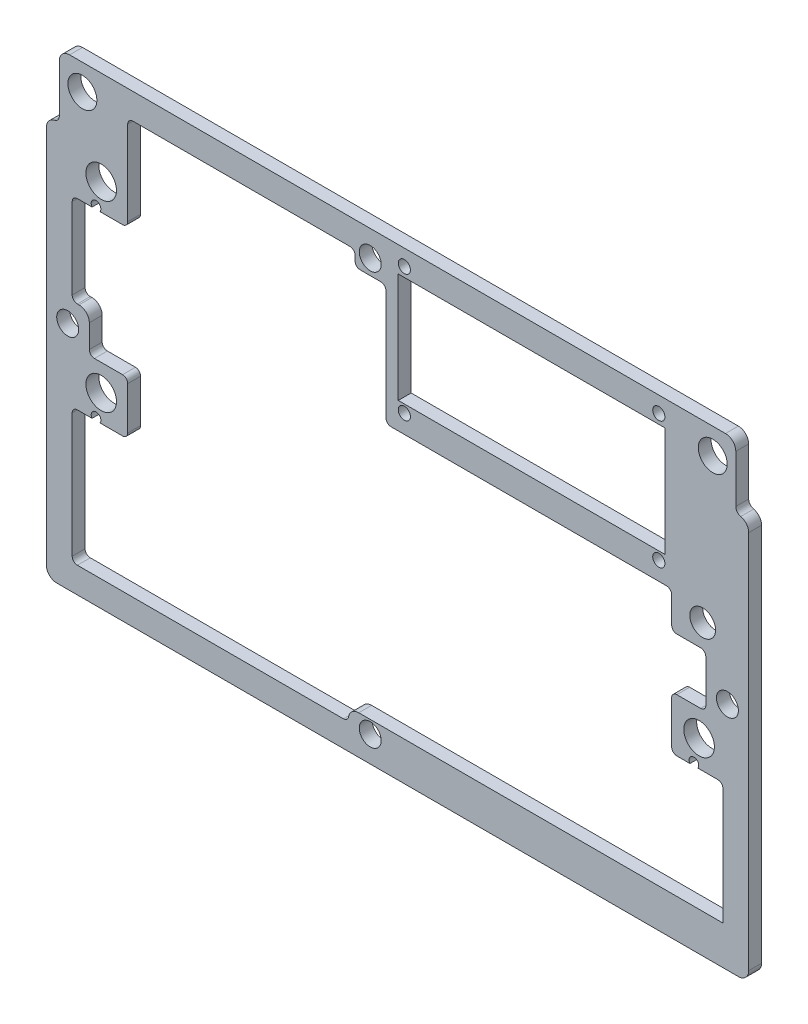
from build123d import *

# Parameters (mm, degrees)
SKETCH1_W                   = 173.0375
SKETCH1_H                   = 114.3
BOSS_EXTRUDE1_DEPTH         = 3.175
SKETCH3_R                   = 3.175
SKETCH3_R_2                 = 3.7703125
CUT_EXTRUDE1_DEPTH          = 4.175
F_6_CLEARANCE_HOLE1_D       = 4.3053
F_2_CLEARANCE_HOLE1_D       = 2.7051
SKETCH8_W                   = 58.74
SKETCH8_H                   = 26.99
CUT_EXTRUDE2_DEPTH          = 4.175
F_3_0_213_DIAMETER_HOLE1_D  = 5.4102
F_3_0_3_DIAMETER_HOLE1_D    = 3
FILLET1_R                   = 1.27
FILLET2_R                   = 2.54
F_1_4_CLEARANCE_HOLE1_D     = 7.14248
F_1_4_CLEARANCE_HOLE1_DEPTH = 3.175
CUT_EXTRUDE3_REACH          = 5.175
SKETCH14_W                  = 3.175
SKETCH14_H                  = 15.875
FILLET3_R                   = 1.5875
FILLET4_R                   = 2.54
CUT_EXTRUDE4_START          = -3.175
SKETCH15_W                  = 65.7
SKETCH15_H                  = 26.99
CUT_EXTRUDE4_DEPTH          = 3.175
CUT_EXTRUDE5_REACH          = 5.175
SKETCH16_R                  = 1.190625


with BuildPart() as part:
    # Sketch1 → Boss-Extrude1 (new body)
    with BuildSketch(Plane.XY):
        with Locations((25.118, -40.513)):
            Rectangle(SKETCH1_W, SKETCH1_H)
    extrude(amount=BOSS_EXTRUDE1_DEPTH)

    # Sketch3 → Cut-Extrude1 (cut, through all)
    with BuildSketch(Plane.XY.offset(3.175)):
        with Locations((100.302, -26.543)):
            Circle(SKETCH3_R)
        with Locations((99.413, -51.6255)):
            Circle(SKETCH3_R_2)
        with Locations((-47.907, -51.6255)):
            Circle(SKETCH3_R_2)
        with Locations((-47.907, -6.5405)):
            Circle(SKETCH3_R_2)
    extrude(amount=-CUT_EXTRUDE1_DEPTH, mode=Mode.SUBTRACT)

    # #6 Clearance Hole1 (through all)
    with Locations(Plane.XY.offset(3.175)):
        with Locations((18.387, 10.287), (-56.162, -40.894), (106.398, -40.894), (18.387, -91.313)):
            Hole(F_6_CLEARANCE_HOLE1_D / 2)

    # #2 Clearance Hole1 (through all)
    with Locations(Plane.XY.offset(3.175)):
        with Locations((26.788, 12.7), (89.488, 12.7), (89.488, -18.6), (26.788, -18.6)):
            Hole(F_2_CLEARANCE_HOLE1_D / 2)

    # Sketch8 → Cut-Extrude2 (cut, through all)
    with BuildSketch(Plane.XY.offset(3.175)):
        with Locations((58.138, -3.125)):
            Rectangle(SKETCH8_W, SKETCH8_H)
        Polygon((14.64685, 6.54685), (14.64685, 10.287), (-41.367, 10.287), (-41.367, -13.0805), (-55.05075, -13.0805), (-55.05075, -35.56635), (-50.83435, -35.56635), (-50.83435, -45.0855), (-41.367, -45.0855), (-41.367, -58.1655), (-55.05075, -58.1655), (-55.05075, -91.313), (13.05935, -91.313), (13.05935, -88.138), (105.28675, -88.138), (105.28675, -58.1655), (92.658, -58.1655), (92.658, -45.0855), (101.07035, -45.0855), (101.07035, -32.150898303), (92.658, -32.150898303), (92.658, -23.12755), (22.26045, -23.12755), (22.26045, 6.54685), align=None)
    extrude(amount=-CUT_EXTRUDE2_DEPTH, mode=Mode.SUBTRACT)

    # #3 (0.213) Diameter Hole1 (through all)
    with Locations(Plane(origin=(18.387, 10.287, 3.175), x_dir=(1, 0, 0), z_dir=(0, 0, 1))):
        with Locations((0, 0), (-74.549, -51.181), (0, -101.6), (88.011, -51.181)):
            Hole(F_3_0_213_DIAMETER_HOLE1_D / 2)

    # Ø3.0 (3) Diameter Hole1 (through all)
    with Locations(Plane.XY.offset(3.175)):
        with Locations((26.788, 12.7), (89.488, 12.7), (89.488, -18.6), (26.788, -18.6)):
            Hole(F_3_0_3_DIAMETER_HOLE1_D / 2)

    # Fillet1
    fillet1_edges = [part.edges().sort_by_distance(p)[0] for p in [
        (14.64685, 10.287, 1.5875),
        (14.64685, 6.54685, 1.5875),
        (22.26045, 6.54685, 1.5875),
        (22.26045, -23.12755, 1.5875),
        (92.658, -23.12755, 1.5875),
        (92.658, -32.150898303, 1.5875),
        (101.07035, -32.150898303, 1.5875),
        (101.07035, -45.0855, 1.5875),
        (92.658, -45.0855, 1.5875),
        (92.658, -58.1655, 1.5875),
        (105.28675, -58.1655, 1.5875),
        (13.05935, -91.313, 1.5875),
        (-55.05075, -91.313, 1.5875),
        (-55.05075, -58.1655, 1.5875),
        (-41.367, -58.1655, 1.5875),
        (-41.367, -45.0855, 1.5875),
        (-50.83435, -45.0855, 1.5875),
        (-55.05075, -35.56635, 1.5875),
        (-55.05075, -13.0805, 1.5875),
        (-41.367, -13.0805, 1.5875),
        (-41.367, 10.287, 1.5875),
    ]]
    fillet(fillet1_edges, radius=FILLET1_R)

    # Fillet2
    fillet2_edges = [part.edges().sort_by_distance(p)[0] for p in [
        (13.05935, -88.138, 1.5875),
        (-50.83435, -35.56635, 1.5875),
        (111.63675, 16.637, 1.5875),
        (111.63675, -97.663, 1.5875),
        (-61.40075, -97.663, 1.5875),
        (-61.40075, 16.637, 1.5875),
    ]]
    fillet(fillet2_edges, radius=FILLET2_R)

    # 1/4 Clearance Hole1
    with Locations(Plane(origin=(0, 0, 0), x_dir=(-1, 0, 0), z_dir=(0, 0, -1))):
        with Locations((-102.7785, 10.287), (52.5425, 10.287)):
            Hole(F_1_4_CLEARANCE_HOLE1_D / 2, depth=F_1_4_CLEARANCE_HOLE1_DEPTH)

    # Sketch14 → Cut-Extrude3 (cut, up to next)
    with BuildSketch(Plane(origin=(0, 0, 0), x_dir=(-1, 0, 0), z_dir=(0, 0, -1)), mode=Mode.PRIVATE) as cut_extrude3_sk1:
        with Locations((-110.04925, 8.6995)):
            Rectangle(SKETCH14_W, SKETCH14_H)
    cut_extrude3_tool1 = extrude(cut_extrude3_sk1.sketch, amount=-CUT_EXTRUDE3_REACH, mode=Mode.PRIVATE) & part.part
    add(cut_extrude3_tool1.solids().sort_by_distance((110.04925, 8.6995, 0))[0], mode=Mode.SUBTRACT)
    # Sketch14 → Cut-Extrude3 (cut, up to next)
    with BuildSketch(Plane(origin=(0, 0, 0), x_dir=(-1, 0, 0), z_dir=(0, 0, -1)), mode=Mode.PRIVATE) as cut_extrude3_sk2:
        with Locations((59.81325, 8.6995)):
            Rectangle(SKETCH14_W, SKETCH14_H)
    cut_extrude3_tool2 = extrude(cut_extrude3_sk2.sketch, amount=-CUT_EXTRUDE3_REACH, mode=Mode.PRIVATE) & part.part
    add(cut_extrude3_tool2.solids().sort_by_distance((-59.81325, 8.6995, 0))[0], mode=Mode.SUBTRACT)

    # Fillet3
    fillet3_edges = [part.edges().sort_by_distance(p)[0] for p in [
        (108.46175, 0.762, 1.5875),
        (-58.22575, 0.762, 1.5875),
    ]]
    fillet(fillet3_edges, radius=FILLET3_R)

    # Fillet4
    fillet4_edges = [part.edges().sort_by_distance(p)[0] for p in [
        (111.63675, 0.762, 1.5875),
        (108.46175, 16.637, 1.5875),
        (-58.22575, 16.637, 1.5875),
        (-61.40075, 0.762, 1.5875),
    ]]
    fillet(fillet4_edges, radius=FILLET4_R)

    # Sketch15 → Cut-Extrude4 (cut)
    with BuildSketch(Plane(origin=(0, 0, 0), x_dir=(-1, 0, 0), z_dir=(0, 0, -1)).offset(CUT_EXTRUDE4_START)):
        with Locations((-58.138, -3.125)):
            Rectangle(SKETCH15_W, SKETCH15_H)
    extrude(amount=CUT_EXTRUDE4_DEPTH, mode=Mode.SUBTRACT)

    # Sketch16 → Cut-Extrude5 (cut, up to next)
    with BuildSketch(Plane(origin=(0, 0, 0), x_dir=(-1, 0, 0), z_dir=(0, 0, -1)), mode=Mode.PRIVATE) as cut_extrude5_sk1:
        with Locations((-98.142490655, -57.489441166)):
            Circle(SKETCH16_R)
    cut_extrude5_tool1 = extrude(cut_extrude5_sk1.sketch, amount=-CUT_EXTRUDE5_REACH, mode=Mode.PRIVATE) & part.part
    add(cut_extrude5_tool1.solids().sort_by_distance((98.142491, -57.489441, 0))[0], mode=Mode.SUBTRACT)
    # Sketch16 → Cut-Extrude5 (cut, up to next)
    with BuildSketch(Plane(origin=(0, 0, 0), x_dir=(-1, 0, 0), z_dir=(0, 0, -1)), mode=Mode.PRIVATE) as cut_extrude5_sk2:
        with Locations((49.177509345, -57.489441166)):
            Circle(SKETCH16_R)
    cut_extrude5_tool2 = extrude(cut_extrude5_sk2.sketch, amount=-CUT_EXTRUDE5_REACH, mode=Mode.PRIVATE) & part.part
    add(cut_extrude5_tool2.solids().sort_by_distance((-49.177509, -57.489441, 0))[0], mode=Mode.SUBTRACT)
    # Sketch16 → Cut-Extrude5 (cut, up to next)
    with BuildSketch(Plane(origin=(0, 0, 0), x_dir=(-1, 0, 0), z_dir=(0, 0, -1)), mode=Mode.PRIVATE) as cut_extrude5_sk3:
        with Locations((49.177509345, -12.404441166)):
            Circle(SKETCH16_R)
    cut_extrude5_tool3 = extrude(cut_extrude5_sk3.sketch, amount=-CUT_EXTRUDE5_REACH, mode=Mode.PRIVATE) & part.part
    add(cut_extrude5_tool3.solids().sort_by_distance((-49.177509, -12.404441, 0))[0], mode=Mode.SUBTRACT)


solid = part.part
